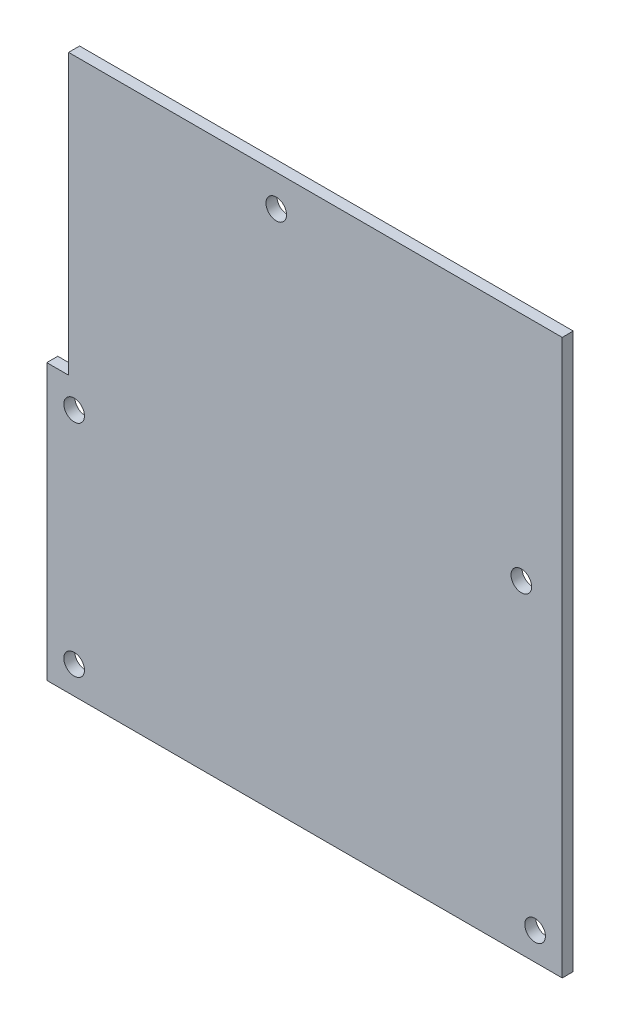
from build123d import *

# Parameters (mm, degrees)
SKETCH1_R           = 1.5
BOSS_EXTRUDE1_DEPTH = 1.6002


with BuildPart() as part:
    # Sketch1 → Boss-Extrude1 (new body)
    with BuildSketch(Plane.XY):
        Polygon((74.93, 80.645), (3.175, 80.645), (3.175, 40.005), (0, 40.005), (0, 0), (74.93, 0), align=None)
        with Locations((68.984, 47.026)):
            Circle(SKETCH1_R, mode=Mode.SUBTRACT)
        with Locations((33.3595, 76.026)):
            Circle(SKETCH1_R, mode=Mode.SUBTRACT)
        with Locations((3.984, 36.026)):
            Circle(SKETCH1_R, mode=Mode.SUBTRACT)
        with Locations((70.984, 4.026)):
            Circle(SKETCH1_R, mode=Mode.SUBTRACT)
        with Locations((3.984, 4.026)):
            Circle(SKETCH1_R, mode=Mode.SUBTRACT)
    extrude(amount=BOSS_EXTRUDE1_DEPTH)


solid = part.part
